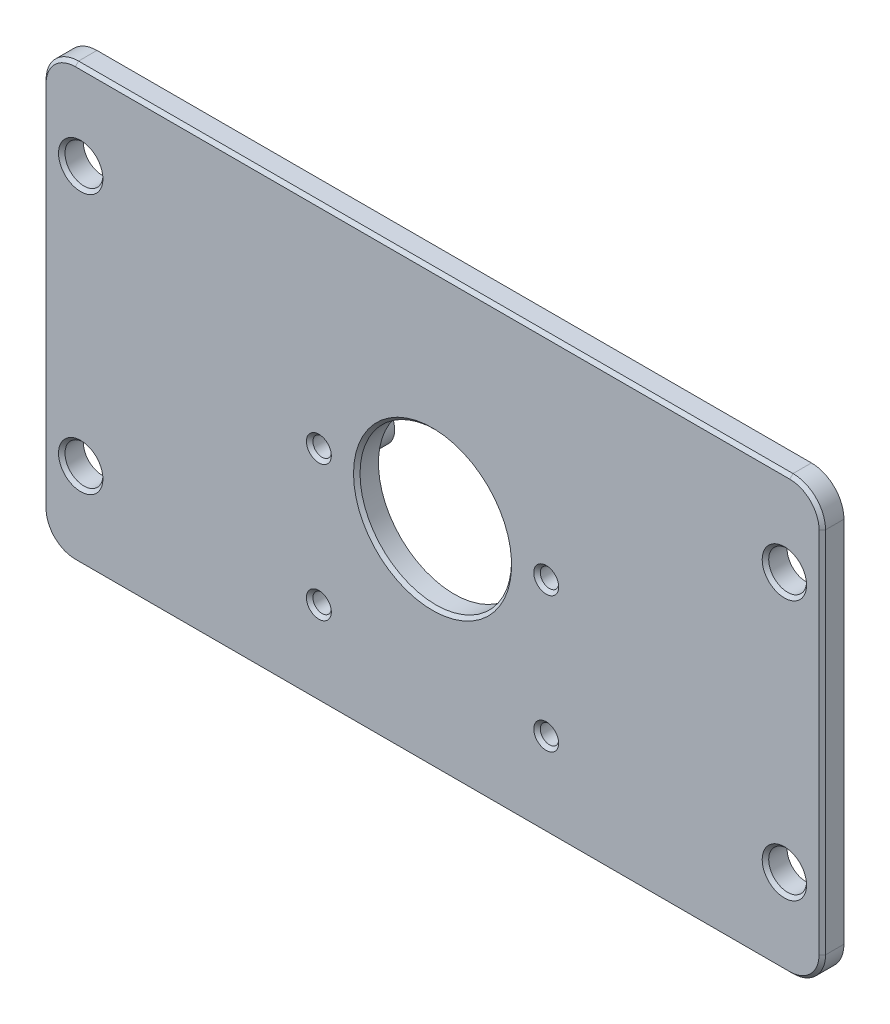
from build123d import *

# Parameters (mm, degrees)
SKETCH_1_W                         = 72
SKETCH_1_H                         = 40
EXTRUDE_1_DEPTH                    = 2
SKETCH_2_R                         = 7
CUT_EXTRUDE_1_DEPTH                = 3
FILLET_1_R                         = 3
SKETCH_5_R                         = 1.75
CUT_EXTRUDE_4_DEPTH                = 3
PATTERN_LINEAR_1_COUNT             = 2
PATTERN_LINEAR_1_PITCH             = 65
PATTERN_LINEAR_1_COUNT_DIR2        = 2
PATTERN_LINEAR_1_PITCH_DIR2        = 24
SKETCH_7_R                         = 2
SKETCH_7_R_2                       = 0.85
EXTRUDE_2_DEPTH                    = 3
SKETCH_8_R                         = 0.85
CUT_EXTRUDE_6_DEPTH                = 6
FILLET_3_R                         = 1
CHAMFER_1_SIZE                     = 0.6
PATTERN_LINEAR_2_COUNT             = 2
PATTERN_LINEAR_2_PITCH             = 12.5
PATTERN_LINEAR_2_COUNT_DIR2        = 2
PATTERN_LINEAR_2_PITCH_DIR2        = 21
FILLET_3_OF_PATTERN_LINEAR_2_R     = 1
CHAMFER_1_OF_PATTERN_LINEAR_2_SIZE = 0.6
CHAMFER_2_SIZE                     = 0.3


with BuildPart() as part:
    # Эскиз1 → Бобышка-Вытянуть1 (new body)
    with BuildSketch(Plane.XY):
        Rectangle(SKETCH_1_W, SKETCH_1_H)
    extrude(amount=EXTRUDE_1_DEPTH)

    # Эскиз2 → Вырез-Вытянуть1 (cut, through all)
    with BuildSketch(Plane.XY.offset(2)):
        Circle(SKETCH_2_R)
    extrude(amount=-CUT_EXTRUDE_1_DEPTH, mode=Mode.SUBTRACT)

    # Скругление1
    fillet_1_edges = [part.edges().sort_by_distance(p)[0] for p in [
        (36, -20, 1),
        (-36, -20, 1),
        (-36, 20, 1),
        (36, 20, 1),
    ]]
    fillet(fillet_1_edges, radius=FILLET_1_R)

    # Эскиз5 → Вырез-Вытянуть4 (cut, through all)
    with BuildSketch(Plane.XY.offset(2)):
        with Locations((-32.5, -12)):
            Circle(SKETCH_5_R)
    cut_extrude_4 = extrude(amount=-CUT_EXTRUDE_4_DEPTH, mode=Mode.SUBTRACT)

    # Линейный массив1: Cut-Extrude 4 2 × 2
    with Locations(*[(i * PATTERN_LINEAR_1_PITCH, j * PATTERN_LINEAR_1_PITCH_DIR2, 0) for i in range(PATTERN_LINEAR_1_COUNT) for j in range(PATTERN_LINEAR_1_COUNT_DIR2) if (i, j) != (0, 0)]):
        add(cut_extrude_4, mode=Mode.SUBTRACT)

    # Эскиз7 → Бобышка-Вытянуть2 (add)
    with BuildSketch(Plane(origin=(0, 0, 0), x_dir=(-1, 0, 0), z_dir=(0, 0, -1))):
        with Locations((-10.5, 0.4)):
            Circle(SKETCH_7_R)
        with Locations((-10.5, 0.4)):
            Circle(SKETCH_7_R_2, mode=Mode.SUBTRACT)
    extrude_2 = extrude(amount=EXTRUDE_2_DEPTH)

    # Эскиз8 → Вырез-Вытянуть6 (cut)
    with BuildSketch(Plane(origin=(0, 0, 0), x_dir=(-1, 0, 0), z_dir=(0, 0, -1))):
        with Locations((-10.5, 0.4)):
            Circle(SKETCH_8_R)
    cut_extrude_6 = extrude(amount=-CUT_EXTRUDE_6_DEPTH, mode=Mode.SUBTRACT)

    # Скругление3
    fillet_3_edges = [part.edges().sort_by_distance(p)[0] for p in [
        (12.5, 0.4, 0),
    ]]
    fillet(fillet_3_edges, radius=FILLET_3_R)

    # Фаска1
    chamfer_1_edges = [part.edges().sort_by_distance(p)[0] for p in [
        (11.35, 0.4, -3),
    ]]
    chamfer(chamfer_1_edges, length=CHAMFER_1_SIZE)

    # Линейный массив2: Бобышка-Вытянуть2, Cut-Extrude 6 2 × 2
    with Locations(*[(-j * PATTERN_LINEAR_2_PITCH_DIR2, -i * PATTERN_LINEAR_2_PITCH, 0) for i in range(PATTERN_LINEAR_2_COUNT) for j in range(PATTERN_LINEAR_2_COUNT_DIR2) if (i, j) != (0, 0)]):
        add(extrude_2)
        add(cut_extrude_6, mode=Mode.SUBTRACT)

    # Скругление3 of Линейный массив2
    fillet_3_of_pattern_linear_2_edges = [part.edges().sort_by_distance(p)[0] for p in [
        (-8.5, 0.4, 0),
        (12.5, -12.1, 0),
        (-8.5, -12.1, 0),
    ]]
    fillet(fillet_3_of_pattern_linear_2_edges, radius=FILLET_3_OF_PATTERN_LINEAR_2_R)

    # Фаска1 of Линейный массив2
    chamfer_1_of_pattern_linear_2_edges = [part.edges().sort_by_distance(p)[0] for p in [
        (-9.65, 0.4, -3),
        (11.35, -12.1, -3),
        (-9.65, -12.1, -3),
    ]]
    chamfer(chamfer_1_of_pattern_linear_2_edges, length=CHAMFER_1_OF_PATTERN_LINEAR_2_SIZE)

    # Фаска2
    chamfer_2_edges = [part.edges().sort_by_distance(p)[0] for p in [
        (11.35, -12.1, 2),
        (-9.65, -12.1, 2),
        (-7, 0, 2),
        (-36, 0, 2),
        (0, 20, 2),
        (36, 0, 2),
        (0, -20, 2),
        (35.121320344, 19.121320344, 2),
        (35.121320344, -19.121320344, 2),
        (-35.121320344, -19.121320344, 2),
        (-35.121320344, 19.121320344, 2),
        (-34.25, -12, 2),
        (30.75, -12, 2),
        (-34.25, 12, 2),
        (30.75, 12, 2),
        (11.35, 0.4, 2),
        (-9.65, 0.4, 2),
    ]]
    chamfer(chamfer_2_edges, length=CHAMFER_2_SIZE)


solid = part.part
